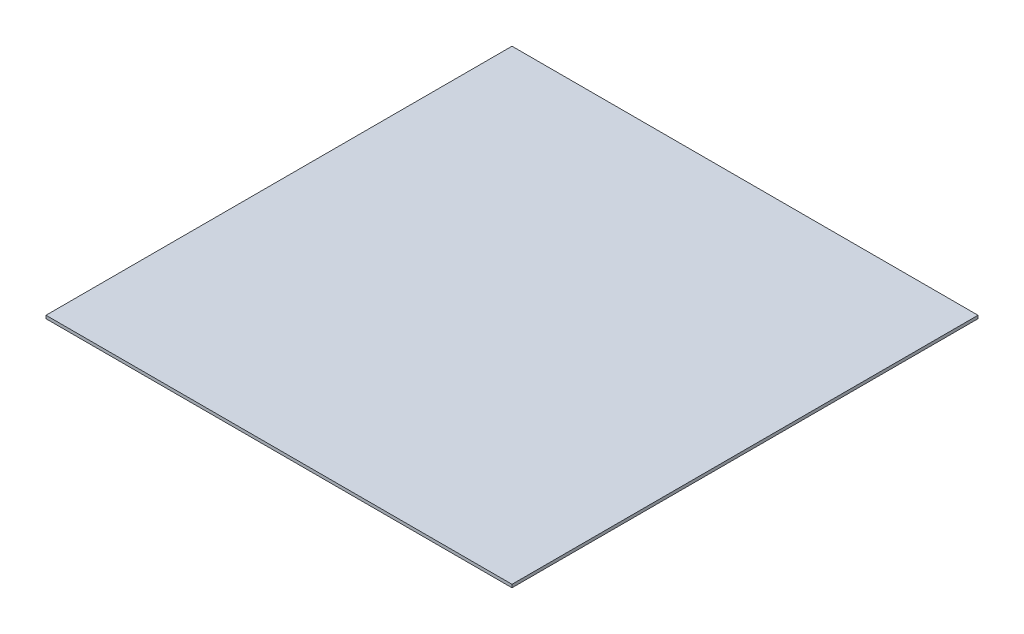
from build123d import *

# Parameters (mm, degrees)
SKETCH1_W           = 304.8
SKETCH1_H           = 304.8
BOSS_EXTRUDE1_DEPTH = 2


with BuildPart() as part:
    # Sketch1 → Boss-Extrude1 (new body)
    with BuildSketch(Plane(origin=(0, 0, 0), x_dir=(1, 0, 0), z_dir=(0, 1, 0))):
        Rectangle(SKETCH1_W, SKETCH1_H)
    extrude(amount=BOSS_EXTRUDE1_DEPTH)


solid = part.part
